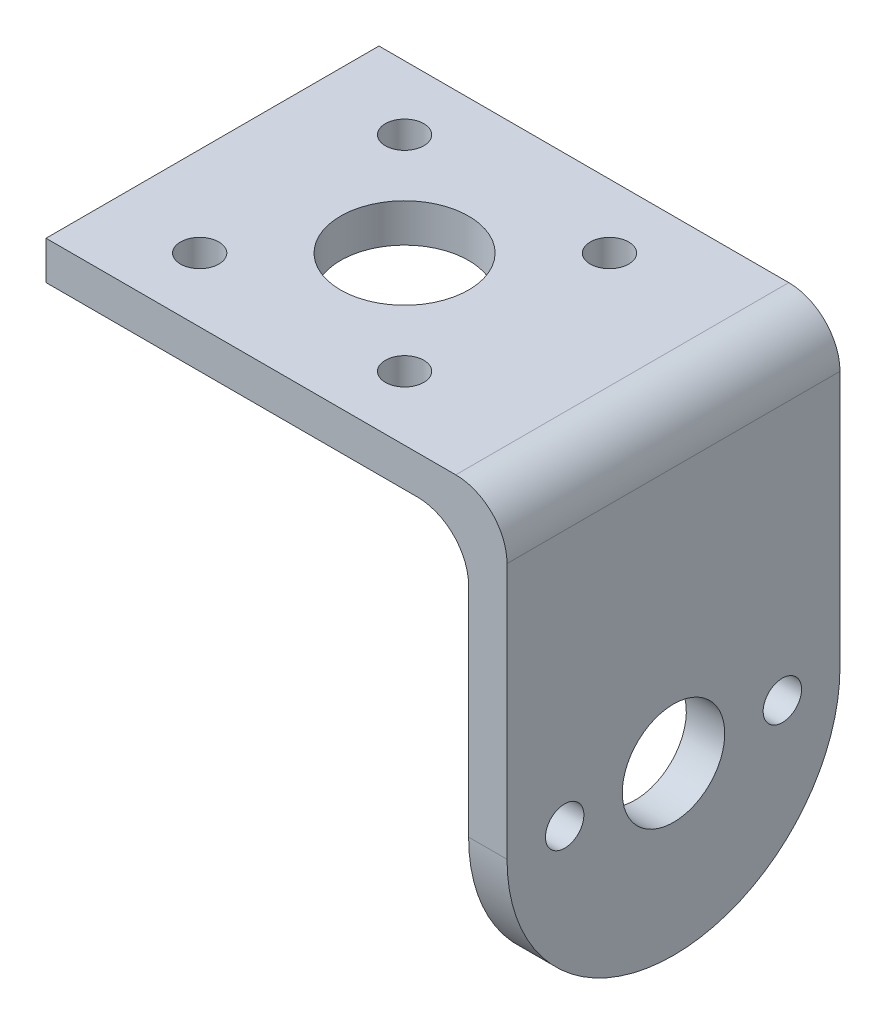
from build123d import *

# Parameters (mm, degrees)
BOSS_EXTRUDE1_DEPTH = 26
SKETCH2_R           = 1.5
SKETCH2_R_2         = 4
CUT_EXTRUDE1_DEPTH  = 26
FILLET1_R           = 4
SKETCH3_R           = 5
SKETCH3_R_2         = 1.5
CUT_EXTRUDE2_DEPTH  = 26


with BuildPart() as part:
    # Sketch1 → Boss-Extrude1 (new body)
    with BuildSketch(Plane.XY):
        Polygon((0, 0), (33, 0), (33, -34), (36, -34), (36, 3), (0, 3), align=None)
    extrude(amount=BOSS_EXTRUDE1_DEPTH)

    # Sketch2 → Cut-Extrude1 (cut)
    with BuildSketch(Plane(origin=(36, 0, 0), x_dir=(0, 0, -1), z_dir=(1, 0, 0))):
        with BuildLine():
            ThreePointArc((-13, -34), (-22.192388155, -30.192388155), (-26, -21))
            Line((-26, -21), (-26, -34))
            Line((-26, -34), (-13, -34))
        make_face()
        with BuildLine():
            ThreePointArc((0, -21), (-3.807611845, -30.192388155), (-13, -34))
            Line((-13, -34), (0, -34))
            Line((0, -34), (0, -21))
        make_face()
        with Locations((-4.5, -21)):
            Circle(SKETCH2_R)
        with Locations((-13, -21)):
            Circle(SKETCH2_R_2)
        with Locations((-21.5, -21)):
            Circle(SKETCH2_R)
    extrude(amount=-CUT_EXTRUDE1_DEPTH, mode=Mode.SUBTRACT)

    # Fillet1
    fillet1_edges = [part.edges().sort_by_distance(p)[0] for p in [
        (36, 3, 13),
        (33, 0, 13),
    ]]
    fillet(fillet1_edges, radius=FILLET1_R)

    # Sketch3 → Cut-Extrude2 (cut)
    with BuildSketch(Plane(origin=(0, 3, 0), x_dir=(1, 0, 0), z_dir=(0, 1, 0))):
        with Locations((15, -13)):
            Circle(SKETCH3_R)
        with Locations((23, -21)):
            Circle(SKETCH3_R_2)
        with Locations((23, -5)):
            Circle(SKETCH3_R_2)
        with Locations((7, -5)):
            Circle(SKETCH3_R_2)
        with Locations((7, -21)):
            Circle(SKETCH3_R_2)
    extrude(amount=-CUT_EXTRUDE2_DEPTH, mode=Mode.SUBTRACT)


solid = part.part
